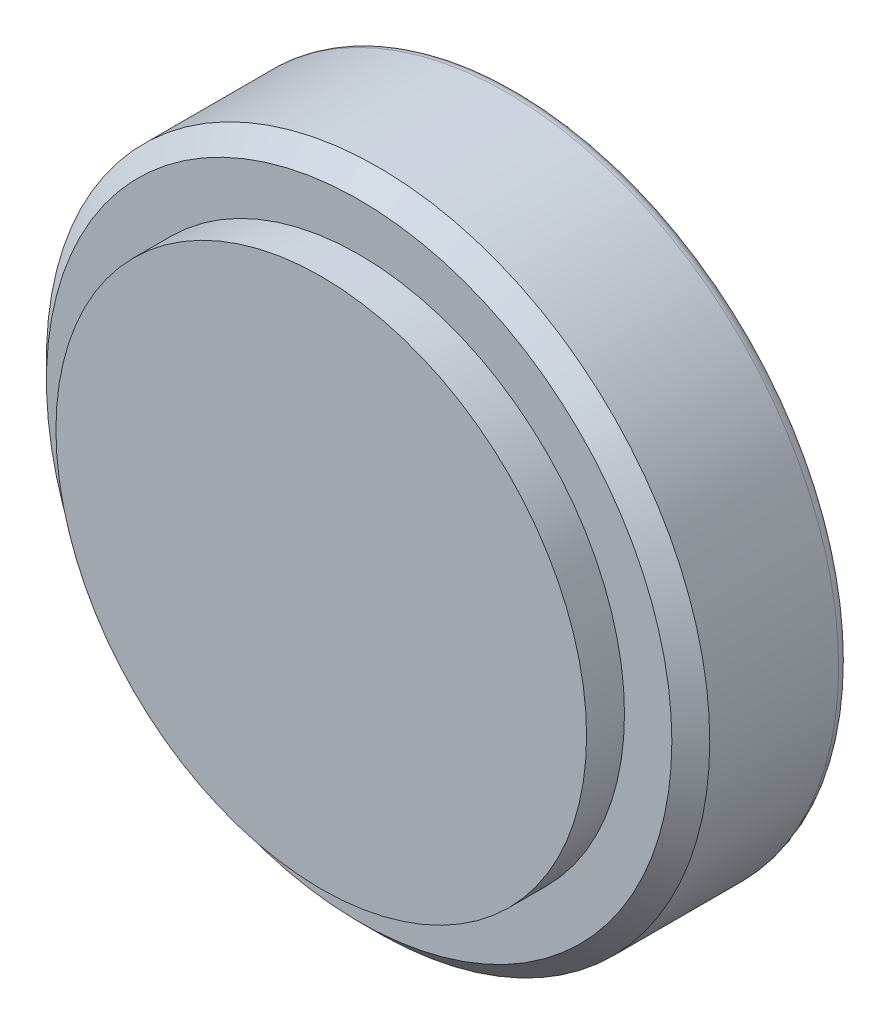
from build123d import *

# Parameters (mm, degrees)
SKETCH1_R           = 87.5
BOSS_EXTRUDE1_DEPTH = 26
SKETCH2_R           = 107.528589123
SKETCH2_R_2         = 70
CUT_EXTRUDE1_DEPTH  = 10
CHAMFER1_SIZE       = 5
FILLET1_R           = 3


with BuildPart() as part:
    # Sketch1 → Boss-Extrude1 (new body, symmetric)
    with BuildSketch(Plane.XY):
        Circle(SKETCH1_R)
    extrude(amount=BOSS_EXTRUDE1_DEPTH, both=True)

    # Sketch2 → Cut-Extrude1 (cut)
    with BuildSketch(Plane.XY.offset(26)):
        Circle(SKETCH2_R)
        Circle(SKETCH2_R_2, mode=Mode.SUBTRACT)
    extrude(amount=-CUT_EXTRUDE1_DEPTH, mode=Mode.SUBTRACT)

    # Chamfer1
    chamfer1_edges = [part.edges().sort_by_distance(p)[0] for p in [
        (-87.5, 0, 16),
    ]]
    chamfer(chamfer1_edges, length=CHAMFER1_SIZE)

    # Fillet1
    fillet1_edges = [part.edges().sort_by_distance(p)[0] for p in [
        (-87.5, 0, -26),
    ]]
    fillet(fillet1_edges, radius=FILLET1_R)


solid = part.part
